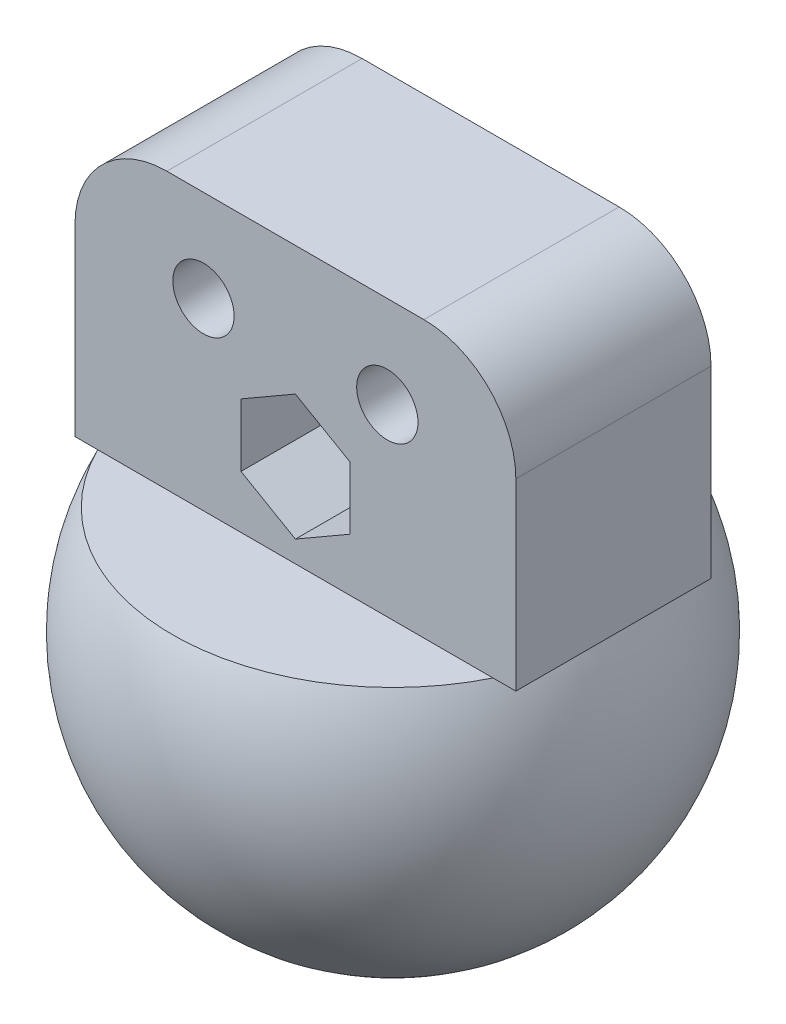
from build123d import *

# Parameters (mm, degrees)
SKETCH2_W               = 28.77498914
SKETCH2_H               = 18
SKETCH2_R               = 2
BOSS_EXTRUDE1_DEPTH     = 6.37
CUT_EXTRUDE1_REACH      = 39.167
SKETCH3_W               = 27.288002312
SKETCH3_H               = 18
CUT_EXTRUDE2_REACH      = 42.089
CUT_EXTRUDE2_START      = -6.37
SKETCH2_2_W             = 28.77498914
SKETCH2_2_H             = 18
SKETCH2_2_R             = 2
FILLET1_R               = 6
CUT_EXTRUDE3_DEPTH      = 34.7194306
CUT_EXTRUDE3_DEPTH_BACK = 34.7194306


with BuildPart() as part:
    # Sketch1 → Revolve1 (revolve)
    with BuildSketch(Plane.XY):
        with BuildLine():
            Line((0, 16), (0, -16))
            ThreePointArc((0, -16), (16, 0), (0, 16))
        make_face()
    revolve(axis=Axis((0, 16, 0), (0, -1, 0)))

    # Sketch2 → Boss-Extrude1 (add, symmetric)
    with BuildSketch(Plane.XY):
        with Locations((0, 16)):
            Rectangle(SKETCH2_W, SKETCH2_H)
        with Locations((-6, 19)):
            Circle(SKETCH2_R, mode=Mode.SUBTRACT)
        with Locations((6, 19)):
            Circle(SKETCH2_R, mode=Mode.SUBTRACT)
        Polygon((0, 16.599186911), (-3.55, 14.549593456), (-3.55, 10.450406544), (0, 8.400813089), (3.55, 10.450406544), (3.55, 14.549593456), align=None, mode=Mode.SUBTRACT)
    extrude(amount=BOSS_EXTRUDE1_DEPTH, both=True)

    # Sketch3 → Cut-Extrude1 (cut, up to next)
    with BuildSketch(Plane.XY.offset(6.37), mode=Mode.PRIVATE) as cut_extrude1_sk1:
        with Locations((-0.743493414, 16)):
            Rectangle(SKETCH3_W, SKETCH3_H)
    cut_extrude1_tool1 = extrude(cut_extrude1_sk1.sketch, amount=CUT_EXTRUDE1_REACH, mode=Mode.PRIVATE) & part.part
    add(cut_extrude1_tool1.solids().sort_by_distance((-0.743493, 16, 6.37))[0], mode=Mode.SUBTRACT)

    # Sketch2_2 → Cut-Extrude2 (cut, up to next)
    with BuildSketch(Plane.XY.offset(CUT_EXTRUDE2_START), mode=Mode.PRIVATE) as cut_extrude2_sk1:
        with Locations((0, 16)):
            Rectangle(SKETCH2_2_W, SKETCH2_2_H)
        with Locations((-6, 19)):
            Circle(SKETCH2_2_R, mode=Mode.SUBTRACT)
        with Locations((6, 19)):
            Circle(SKETCH2_2_R, mode=Mode.SUBTRACT)
    cut_extrude2_tool1 = extrude(cut_extrude2_sk1.sketch, amount=-CUT_EXTRUDE2_REACH, mode=Mode.PRIVATE) & part.part
    add(cut_extrude2_tool1.solids().sort_by_distance((0, 15.847006, -6.37))[0], mode=Mode.SUBTRACT)

    # Fillet1
    fillet1_edges = [part.edges().sort_by_distance(p)[0] for p in [
        (-14.38749457, 25, 0),
        (14.38749457, 25, 0),
    ]]
    fillet(fillet1_edges, radius=FILLET1_R)

    # Sketch2_3 → Cut-Extrude3 (cut, two sides: drawn at the far end of the back side and taken through both)
    with BuildSketch(Plane.XY.offset(-CUT_EXTRUDE3_DEPTH_BACK)):
        Polygon((0, 16.599186911), (-3.55, 14.549593456), (-3.55, 10.450406544), (0, 8.400813089), (3.55, 10.450406544), (3.55, 14.549593456), align=None)
    extrude(amount=CUT_EXTRUDE3_DEPTH + CUT_EXTRUDE3_DEPTH_BACK, mode=Mode.SUBTRACT)


solid = part.part
